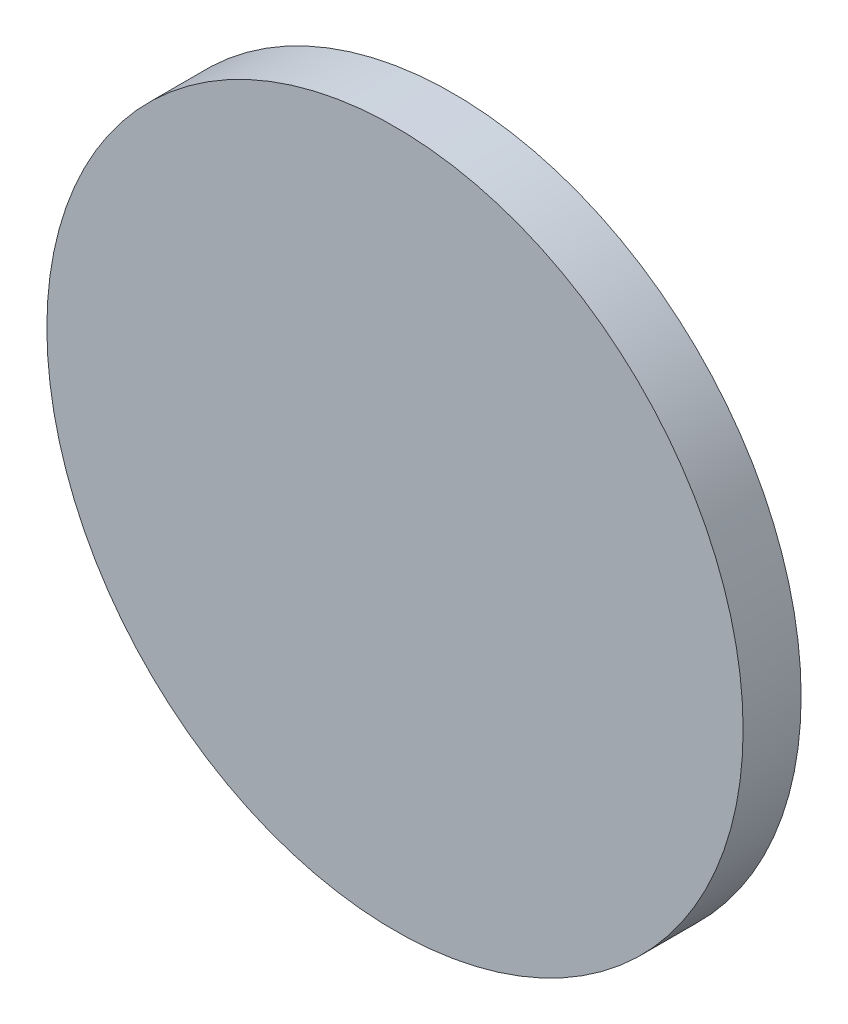
from build123d import *

# Parameters (mm, degrees)
SKETCH1_R           = 38.1
BOSS_EXTRUDE1_DEPTH = 6.35


with BuildPart() as part:
    # Sketch1 → Boss-Extrude1 (new body)
    with BuildSketch(Plane.XY):
        Circle(SKETCH1_R)
    extrude(amount=BOSS_EXTRUDE1_DEPTH)


solid = part.part
